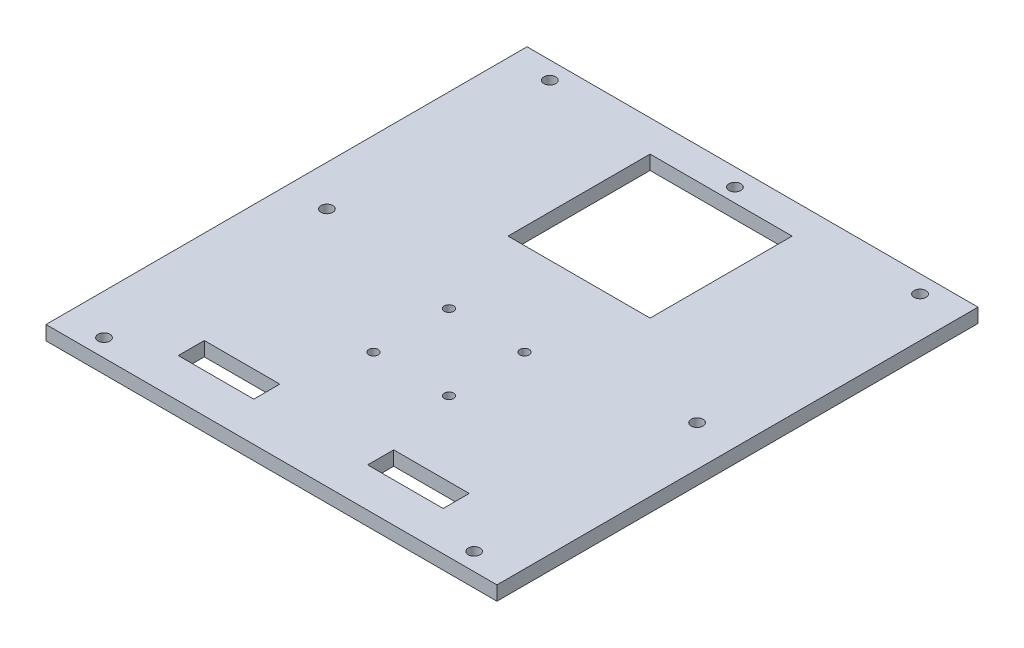
from build123d import *

# Parameters (mm, degrees)
SKETCH2_W           = 190.5
SKETCH2_H           = 203.2
BOSS_EXTRUDE1_DEPTH = 6
SKETCH5_R           = 2.5
CUT_EXTRUDE6_DEPTH  = 7
SKETCH6_W           = 31.9
SKETCH6_H           = 11
SKETCH6_R           = 2
CUT_EXTRUDE8_DEPTH  = 10


with BuildPart() as part:
    # Sketch2 → Boss-Extrude1 (new body)
    with BuildSketch(Plane(origin=(0, 0, 0), x_dir=(1, 0, 0), z_dir=(0, 1, 0))):
        Rectangle(SKETCH2_W, SKETCH2_H)
    extrude(amount=BOSS_EXTRUDE1_DEPTH)

    # Sketch5 → Cut-Extrude6 (cut, through all)
    with BuildSketch(Plane(origin=(0, 6, 0), x_dir=(1, 0, 0), z_dir=(0, 1, 0))):
        with Locations((-78.187036158, 94.165073798)):
            Circle(SKETCH5_R)
        with Locations((0, 94.165073798)):
            Circle(SKETCH5_R)
        with Locations((78.187036158, 0)):
            Circle(SKETCH5_R)
        with Locations((-78.187036158, 0)):
            Circle(SKETCH5_R)
        with Locations((78.187036158, 94.165073798)):
            Circle(SKETCH5_R)
        with Locations((-78.187036158, -94.165073798)):
            Circle(SKETCH5_R)
        with Locations((78.187036158, -94.165073798)):
            Circle(SKETCH5_R)
    extrude(amount=-CUT_EXTRUDE6_DEPTH, mode=Mode.SUBTRACT)

    # Sketch6 → Cut-Extrude8 (cut)
    with BuildSketch(Plane(origin=(0, 6, 0), x_dir=(1, 0, 0), z_dir=(0, 1, 0))):
        with Locations((-40, -79.526039011)):
            Rectangle(SKETCH6_W, SKETCH6_H)
        Polygon((-30, 28.326034404), (-15.95, 28.326034404), (20, 28.326034404), (30, 28.326034404), (30, 88.326034404), (-30, 88.326034404), align=None)
        with Locations((40, -79.526039011)):
            Rectangle(SKETCH6_W, SKETCH6_H)
        with Locations((15.95, -10.676039011)):
            Circle(SKETCH6_R)
        with Locations((-15.95, -10.676039011)):
            Circle(SKETCH6_R)
        with Locations((-15.95, -42.576039011)):
            Circle(SKETCH6_R)
        with Locations((15.95, -42.576039011)):
            Circle(SKETCH6_R)
    extrude(amount=-CUT_EXTRUDE8_DEPTH, mode=Mode.SUBTRACT)


solid = part.part
